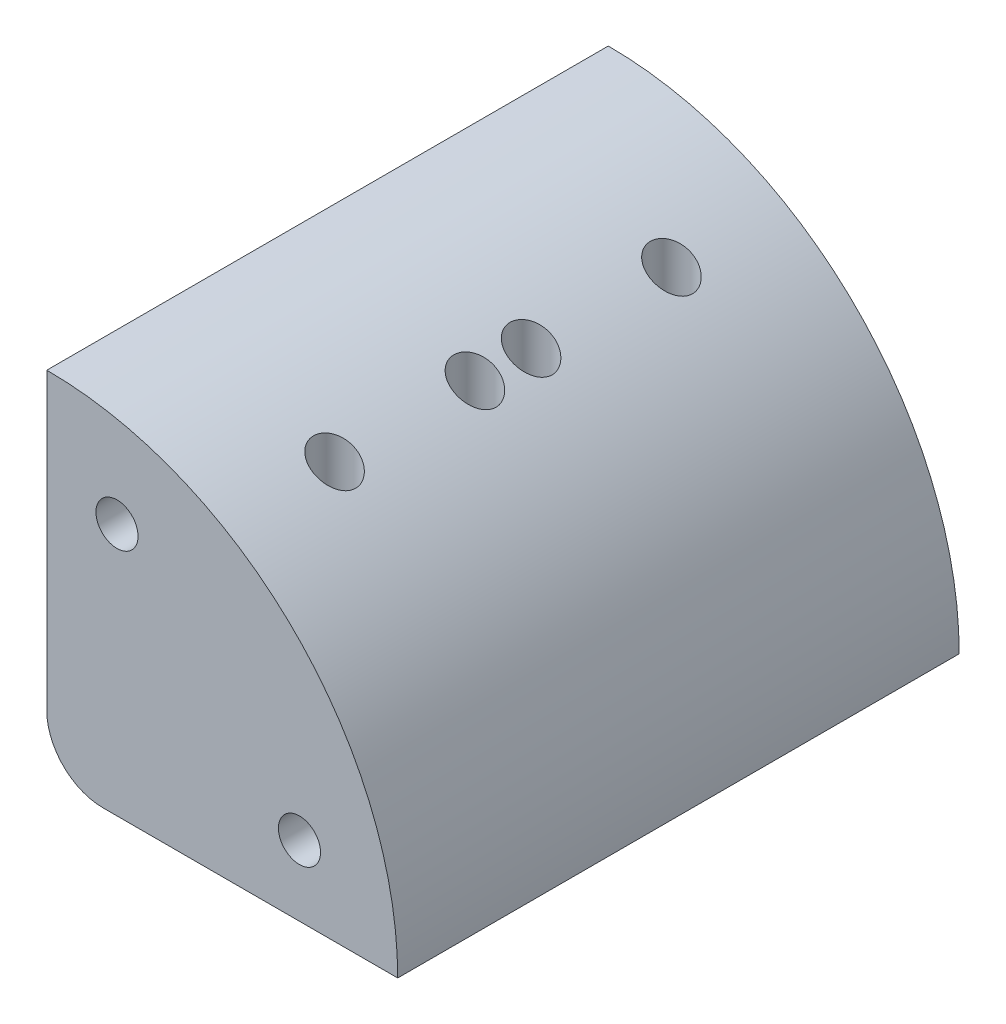
from build123d import *

# Parameters (mm, degrees)
RESSALTO_EXTRUS_O3_DEPTH = 40
ESBO_O8_R                = 1.5
CORTE_EXTRUS_O1_DEPTH    = 40
ESBO_O9_R                = 1.5
CORTE_EXTRUS_O2_DEPTH    = 26


with BuildPart() as part:
    # Esboço7 → Ressalto-extrusão3 (new body)
    with BuildSketch(Plane.XY):
        with BuildLine():
            Line((103.35727616, -256.335501283), (87.35727616, -256.335501283))
            ThreePointArc((87.35727616, -256.335501283), (84.528849035, -255.163928408), (83.35727616, -252.335501283))
            Line((83.35727616, -252.335501283), (83.35727616, -236.335501283))
            Line((83.35727616, -236.335501283), (83.35727616, -231.335501283))
            ThreePointArc((83.35727616, -231.335501283), (101.034945689, -238.657831753), (108.35727616, -256.335501283))
            Line((108.35727616, -256.335501283), (103.35727616, -256.335501283))
        make_face()
    extrude(amount=RESSALTO_EXTRUS_O3_DEPTH)

    # Esboço8 → Corte-extrusão1 (cut)
    with BuildSketch(Plane(origin=(0, 0, 0), x_dir=(-1, 0, 0), z_dir=(0, 0, -1))):
        with Locations((-88.35727616, -238.335501283)):
            Circle(ESBO_O8_R)
        with Locations((-101.35727616, -251.335501283)):
            Circle(ESBO_O8_R)
    extrude(amount=-CORTE_EXTRUS_O1_DEPTH, mode=Mode.SUBTRACT)

    # Esboço9 → Corte-extrusão2 (cut, through all)
    with BuildSketch(Plane.XZ.offset(256.335501283)):
        with Locations((95.85727616, 8)):
            Circle(ESBO_O9_R)
        with Locations((95.85727616, 18)):
            Circle(ESBO_O9_R)
        with Locations((95.85727616, 22)):
            Circle(ESBO_O9_R)
        with Locations((95.85727616, 32)):
            Circle(ESBO_O9_R)
    extrude(amount=-CORTE_EXTRUS_O2_DEPTH, mode=Mode.SUBTRACT)


solid = part.part
